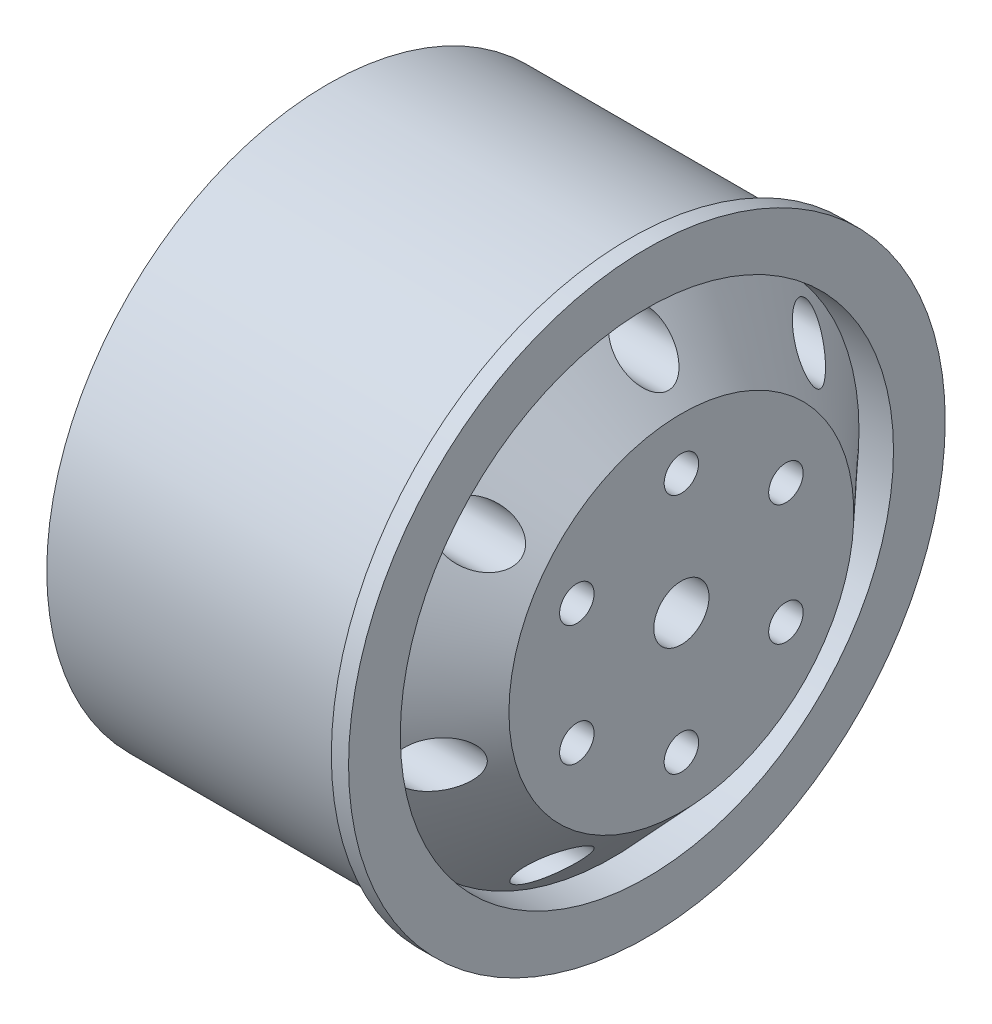
from build123d import *

# Parameters (mm, degrees)
SKETCH2_R          = 1.6
SKETCH2_R_2        = 1
SKETCH2_R_3        = 1.5
CUT_EXTRUDE2_DEPTH = 8


with BuildPart() as part:
    # Sketch1 → Revolve1 (revolve)
    with BuildSketch(Plane(origin=(0, 0, 0), x_dir=(1, 0, 0), z_dir=(0, 1, 0))):
        Polygon((7.516806723, 16.3), (-9.983193277, 16.3), (-9.983193277, 13.3), (3.068446624, 13.602373048), (7.516806723, 8.820385942), (7.516806723, 0), (10.516806723, 0), (10.516806723, 10), (6.516806723, 14.3), (8.516806723, 14.3), (8.516806723, 16.3), (8.516806723, 17.3), (7.516806723, 17.3), align=None)
    revolve(axis=Axis((-9.075630252, 0, 0), (1, 0, 0)))

    # Sketch2 → Cut-Extrude2 (cut)
    with BuildSketch(Plane(origin=(10.516806723, 0, 0), x_dir=(0, 0, -1), z_dir=(1, 0, 0))):
        Circle(SKETCH2_R)
        with Locations((0, 7)):
            Circle(SKETCH2_R_2)
        with Locations((6.062177826, 3.5)):
            Circle(SKETCH2_R_2)
        with Locations((6.062177826, -3.5)):
            Circle(SKETCH2_R_2)
        with Locations((0, -7)):
            Circle(SKETCH2_R_2)
        with Locations((-6.062177826, -3.5)):
            Circle(SKETCH2_R_2)
        with Locations((-6.062177826, 3.5)):
            Circle(SKETCH2_R_2)
        with Locations((0, 12.3)):
            Circle(SKETCH2_R_3)
        with Locations((9.616527234, 7.668924563)):
            Circle(SKETCH2_R_3)
        with Locations((11.99161332, -2.737007488)):
            Circle(SKETCH2_R_3)
        with Locations((5.336769991, -11.081917075)):
            Circle(SKETCH2_R_3)
        with Locations((-5.336769991, -11.081917075)):
            Circle(SKETCH2_R_3)
        with Locations((-11.99161332, -2.737007488)):
            Circle(SKETCH2_R_3)
        with Locations((-9.616527234, 7.668924563)):
            Circle(SKETCH2_R_3)
    extrude(amount=-CUT_EXTRUDE2_DEPTH, mode=Mode.SUBTRACT)


solid = part.part
